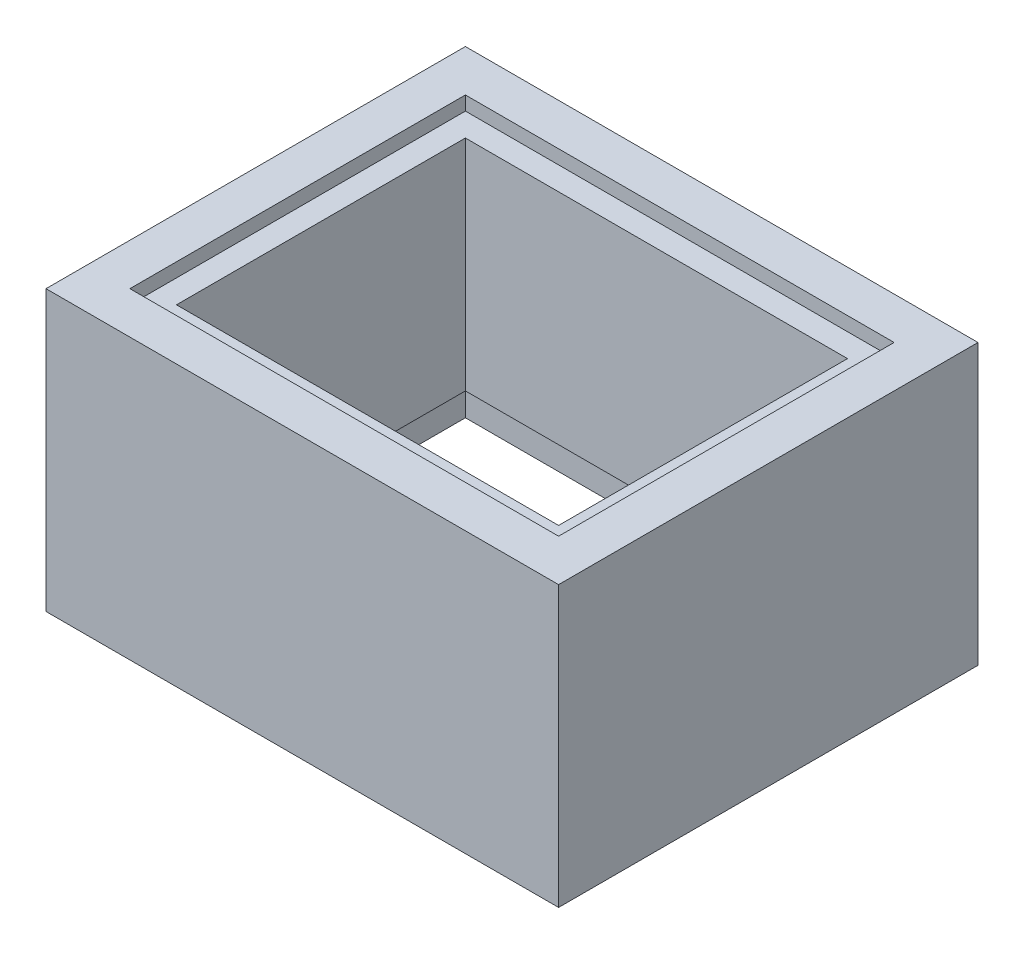
from build123d import *

# Parameters (mm, degrees)
SKETCH2_W           = 110
SKETCH2_H           = 90
BOSS_EXTRUDE2_DEPTH = 60
SKETCH5_W           = 92
SKETCH5_H           = 72
CUT_EXTRUDE3_DEPTH  = 3
SKETCH6_W           = 92
SKETCH6_H           = 72
CUT_EXTRUDE4_DEPTH  = 10
SKETCH7_W           = 82
SKETCH7_H           = 62
CUT_EXTRUDE5_DEPTH  = 60


with BuildPart() as part:
    # Sketch2 → Boss-Extrude2 (new body)
    with BuildSketch(Plane(origin=(0, 0, 0), x_dir=(1, 0, 0), z_dir=(0, 1, 0))):
        with Locations((55, 45)):
            Rectangle(SKETCH2_W, SKETCH2_H)
    extrude(amount=BOSS_EXTRUDE2_DEPTH)

    # Sketch5 → Cut-Extrude3 (cut)
    with BuildSketch(Plane(origin=(0, 60, 0), x_dir=(1, 0, 0), z_dir=(0, 1, 0))):
        with Locations((55, 45)):
            Rectangle(SKETCH5_W, SKETCH5_H)
    extrude(amount=-CUT_EXTRUDE3_DEPTH, mode=Mode.SUBTRACT)

    # Sketch6 → Cut-Extrude4 (cut)
    with BuildSketch(Plane.XZ):
        with Locations((55, -45)):
            Rectangle(SKETCH6_W, SKETCH6_H)
    extrude(amount=-CUT_EXTRUDE4_DEPTH, mode=Mode.SUBTRACT)

    # Sketch7 → Cut-Extrude5 (cut)
    with BuildSketch(Plane(origin=(0, 57, 0), x_dir=(1, 0, 0), z_dir=(0, 1, 0))):
        with Locations((55, 45)):
            Rectangle(SKETCH7_W, SKETCH7_H)
    extrude(amount=-CUT_EXTRUDE5_DEPTH, mode=Mode.SUBTRACT)


solid = part.part
